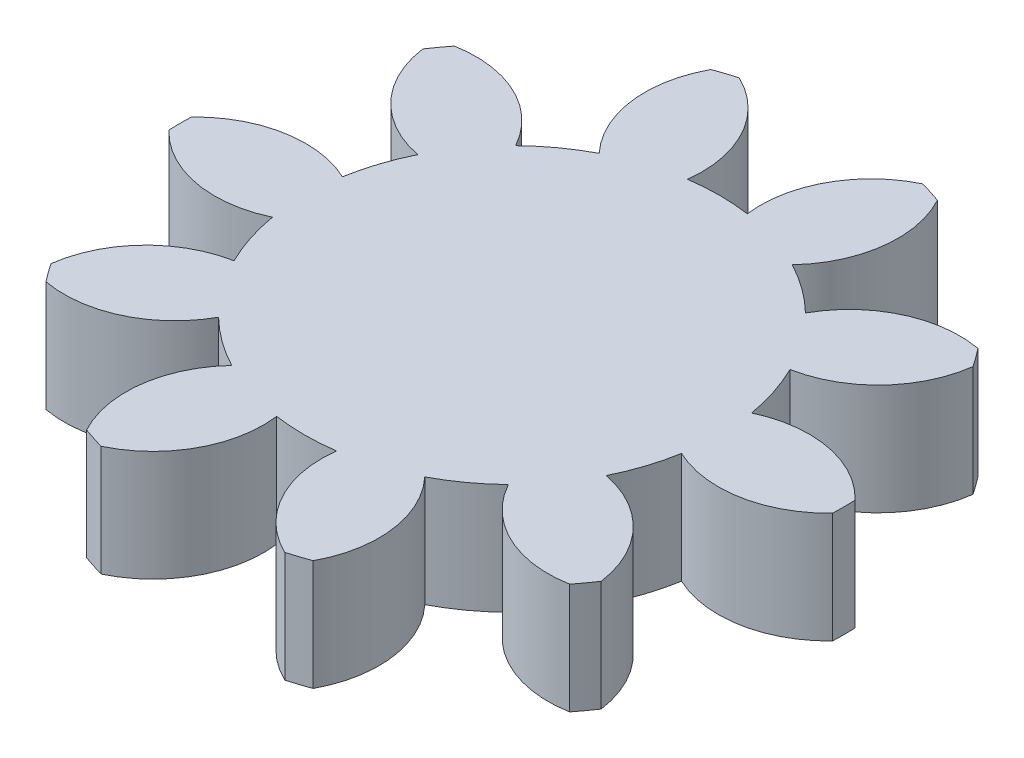
from build123d import *

# Parameters (mm, degrees)
SKETCH1_R           = 9
BOSS_EXTRUDE1_DEPTH = 3
CUT_EXTRUDE1_DEPTH  = 4
CIRPATTERN1_COUNT   = 10


with BuildPart() as part:
    # Sketch1 → Boss-Extrude1 (new body)
    with BuildSketch(Plane(origin=(0, 0, 0), x_dir=(1, 0, 0), z_dir=(0, 1, 0))):
        Circle(SKETCH1_R)
    extrude(amount=BOSS_EXTRUDE1_DEPTH)

    # Sketch2 → Cut-Extrude1 (cut, through all)
    with BuildSketch(Plane(origin=(0, 3, 0), x_dir=(1, 0, 0), z_dir=(0, 1, 0))):
        with BuildLine():
            ThreePointArc((-2.489254397, 8.648908171), (0, 9), (2.489254397, 8.648908171))
            ThreePointArc((2.489254397, 8.648908171), (1.152028564, 7.378729724), (0.810569881, 5.566291536))
            ThreePointArc((0.810569881, 5.566291536), (0, 5.625), (-0.810569881, 5.566291536))
            ThreePointArc((-0.810569881, 5.566291536), (-1.152028564, 7.378729724), (-2.489254397, 8.648908171))
        make_face()
    cut_extrude1 = extrude(amount=-CUT_EXTRUDE1_DEPTH, mode=Mode.SUBTRACT)

    # CirPattern1: Cut-Extrude1 ×10 about axis
    cirpattern1_axis = Axis((0, 0, 0), (0, 1, 0))
    for i in range(1, CIRPATTERN1_COUNT):
        add(cut_extrude1.rotate(cirpattern1_axis, i * 360 / CIRPATTERN1_COUNT), mode=Mode.SUBTRACT)


solid = part.part
